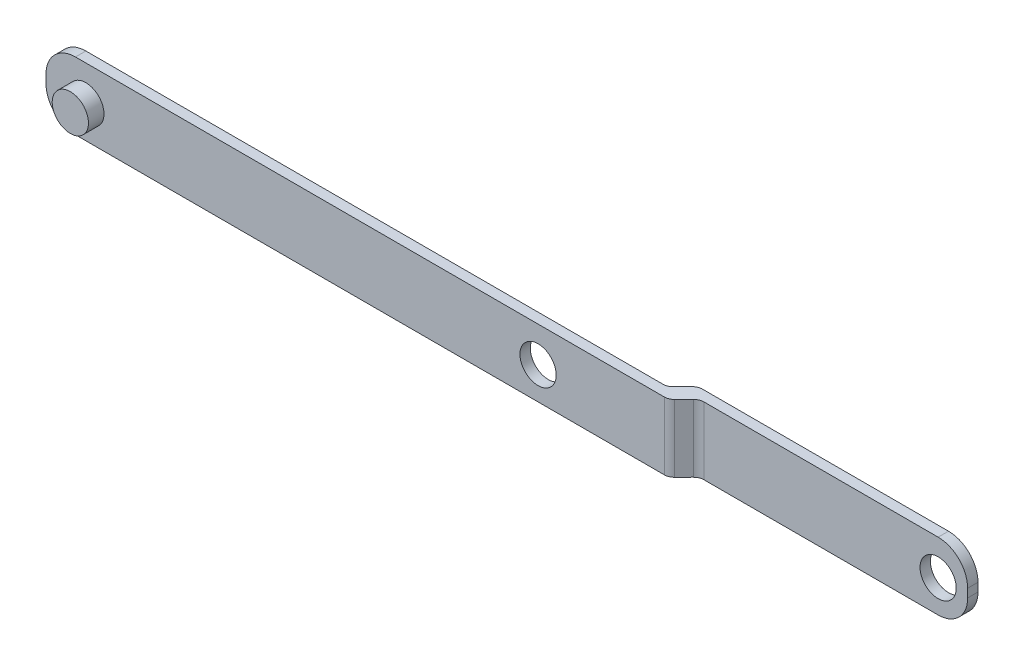
from build123d import *

# Parameters (mm, degrees)
SKETCH1_R           = 3.5
BOSS_EXTRUDE6_DEPTH = 5
CUT_EXTRUDE5_DEPTH  = 14.035691085
FILLET3_R           = 2
SKETCH3_R           = 3.5
BOSS_EXTRUDE9_DEPTH = 3


with BuildPart() as part:
    # Sketch1 → Boss-Extrude6 (new body)
    with BuildSketch(Plane.XY):
        with BuildLine():
            Line((1.138484568, -6.230529798), (82.159951164, -6.236480839))
            ThreePointArc((82.159951164, -6.236480839), (86.188937946, -4.567966564), (87.858044062, -0.539224931))
            Line((87.858044062, -0.539224931), (87.858163632, 1.088682041))
            ThreePointArc((87.858163632, 1.088682041), (86.189649357, 5.117668823), (82.160907724, 6.786774939))
            Line((82.160907724, 6.786774939), (8.344270935, 6.792196785))
            Line((8.344270935, 6.792196785), (-81.443742997, 6.79879173))
            ThreePointArc((-81.443742997, 6.79879173), (-85.472729779, 5.130277455), (-87.141835896, 1.101535822))
            Line((-87.141835896, 1.101535822), (-87.141955466, -0.52637115))
            ThreePointArc((-87.141955466, -0.52637115), (-85.473441191, -4.555357932), (-81.444699558, -6.224464049))
            Line((-81.444699558, -6.224464049), (1.138484568, -6.230529798))
        make_face()
        with Locations((82.160369659, 0)):
            Circle(SKETCH1_R, mode=Mode.SUBTRACT)
        with Locations((7.893112659, 0)):
            Circle(SKETCH1_R, mode=Mode.SUBTRACT)
    extrude(amount=BOSS_EXTRUDE6_DEPTH)

    # Sketch4 → Cut-Extrude5 (cut, through all)
    with BuildSketch(Plane(origin=(0.000498933, 6.792809636, 0), x_dir=(0.999999997, -7.345e-05, 0), z_dir=(7.345e-05, 0.999999997, 0))):
        Polygon((-97.188212117, 0), (-97.188212117, -3), (30.840558875, -3), (33.809433044, 0), align=None)
        Polygon((36.07564421, -2), (33.106770041, -5), (91.140577756, -5), (91.140577756, -2), align=None)
    extrude(amount=-CUT_EXTRUDE5_DEPTH, mode=Mode.SUBTRACT)

    # Fillet3
    fillet3_edges = [part.edges().sort_by_distance(p)[0] for p in [
        (33.809453605, 0.278698438, 0),
        (30.840579445, 0.278916502, 3),
        (33.106790605, 0.278750049, 5),
        (36.075664766, 0.278531984, 2),
    ]]
    fillet(fillet3_edges, radius=FILLET3_R)

    # Sketch3 → Boss-Extrude9 (add)
    with BuildSketch(Plane.XY.offset(5)):
        with Locations((-79.441895681, 0)):
            Circle(SKETCH3_R)
    extrude(amount=BOSS_EXTRUDE9_DEPTH)


solid = part.part
